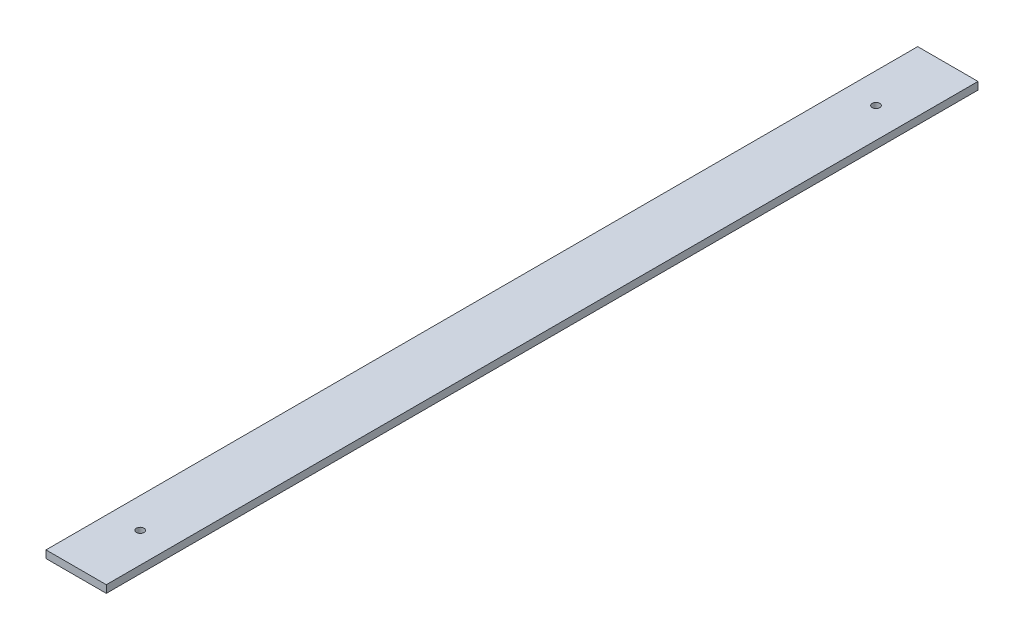
from build123d import *

# Parameters (mm, degrees)
SKETCH4_W             = 200
SKETCH4_H             = 2933.573874127
SKETCH4_R             = 12.5
BOSS_EXTRUDE1_DEPTH   = 25
SKETCH4_H_2           = 2891.000919938
BOSS_EXTRUDE1_2_DEPTH = 25
SKETCH4_H_3           = 2656.8496719
BOSS_EXTRUDE1_3_DEPTH = 25
SKETCH4_H_4           = 2167.26069873
BOSS_EXTRUDE1_4_DEPTH = 25
SKETCH4_H_5           = 1693.636583381
BOSS_EXTRUDE1_5_DEPTH = 25
SKETCH5_W             = 4494.406695046
SKETCH5_H             = 4741.158435166
SKETCH5_W_2           = 1974.013920961
SKETCH5_H_2           = 6468.420616006
CUT_EXTRUDE1_DEPTH    = 10
SKETCH6_W             = 3512.97770999
SKETCH6_H             = 3727.07108035
SKETCH6_W_2           = 1146.73724468
SKETCH6_H_2           = 4594.268007597
CUT_EXTRUDE2_DEPTH    = 26


with BuildPart() as part:
    # Sketch4 → Boss-Extrude1 (new body)
    with BuildSketch(Plane(origin=(0, 0, 0), x_dir=(1, 0, 0), z_dir=(0, 1, 0))):
        with Locations((23132.944645813, -11409.369811035)):
            Rectangle(SKETCH4_W, SKETCH4_H)
        with Locations((23132.944645813, -12678.089615367)):
            Circle(SKETCH4_R, mode=Mode.SUBTRACT)
        with Locations((23132.944645813, -10181.030459334)):
            Circle(SKETCH4_R, mode=Mode.SUBTRACT)
    extrude(amount=BOSS_EXTRUDE1_DEPTH)


with BuildPart() as body_2:
    # Sketch4 → Boss-Extrude1 2 (new body)
    with BuildSketch(Plane(origin=(0, 0, 0), x_dir=(1, 0, 0), z_dir=(0, 1, 0))):
        with Locations((22032.944645813, -11388.083333941)):
            Rectangle(SKETCH4_W, SKETCH4_H_2)
        with Locations((22032.944645813, -12621.228285175)):
            Circle(SKETCH4_R, mode=Mode.SUBTRACT)
        with Locations((22032.944645813, -10181.030459334)):
            Circle(SKETCH4_R, mode=Mode.SUBTRACT)
    extrude(amount=BOSS_EXTRUDE1_2_DEPTH)


with BuildPart() as body_3:
    # Sketch4 → Boss-Extrude1 3 (new body)
    with BuildSketch(Plane(origin=(0, 0, 0), x_dir=(1, 0, 0), z_dir=(0, 1, 0))):
        with Locations((20832.944645813, -11271.007709922)):
            Rectangle(SKETCH4_W, SKETCH4_H_3)
        with Locations((20832.944645813, -12348.754240871)):
            Circle(SKETCH4_R, mode=Mode.SUBTRACT)
        with Locations((20832.944645813, -10181.030459334)):
            Circle(SKETCH4_R, mode=Mode.SUBTRACT)
    extrude(amount=BOSS_EXTRUDE1_3_DEPTH)


with BuildPart() as body_4:
    # Sketch4 → Boss-Extrude1 4 (new body)
    with BuildSketch(Plane(origin=(0, 0, 0), x_dir=(1, 0, 0), z_dir=(0, 1, 0))):
        with Locations((19632.944645813, -11026.213223337)):
            Rectangle(SKETCH4_W, SKETCH4_H_4)
        with Locations((19632.944645813, -11826.915448153)):
            Circle(SKETCH4_R, mode=Mode.SUBTRACT)
        with Locations((19632.944645813, -10181.030459334)):
            Circle(SKETCH4_R, mode=Mode.SUBTRACT)
    extrude(amount=BOSS_EXTRUDE1_4_DEPTH)


with BuildPart() as body_5:
    # Sketch4 → Boss-Extrude1 5 (new body)
    with BuildSketch(Plane(origin=(0, 0, 0), x_dir=(1, 0, 0), z_dir=(0, 1, 0))):
        with Locations((18802.944645813, -10789.401165663)):
            Rectangle(SKETCH4_W, SKETCH4_H_5)
        with Locations((18802.944645813, -11283.669778774)):
            Circle(SKETCH4_R, mode=Mode.SUBTRACT)
        with Locations((18802.944645813, -10181.030459334)):
            Circle(SKETCH4_R, mode=Mode.SUBTRACT)
    extrude(amount=BOSS_EXTRUDE1_5_DEPTH)


with BuildPart() as cut_extrude1_tool:
    # Sketch5 → Cut-Extrude1 (new body)
    with BuildSketch(Plane(origin=(0, 0, 0), x_dir=(1, 0, 0), z_dir=(0, 1, 0))):
        with Locations((19231.869902825, -10968.741703678)):
            Rectangle(SKETCH5_W, SKETCH5_H)
        with Locations((23594.088165664, -11444.620059624)):
            Rectangle(SKETCH5_W_2, SKETCH5_H_2)
    extrude(amount=CUT_EXTRUDE1_DEPTH)


with BuildPart() as part_1:
    add(part.part)

    # Cut-Extrude1: cut by cut_extrude1_tool
    add(cut_extrude1_tool.part, mode=Mode.SUBTRACT)


with BuildPart() as body_3_1:
    add(body_3.part)

    # Cut-Extrude1: cut by cut_extrude1_tool
    add(cut_extrude1_tool.part, mode=Mode.SUBTRACT)


with BuildPart() as body_4_1:
    add(body_4.part)

    # Cut-Extrude1: cut by cut_extrude1_tool
    add(cut_extrude1_tool.part, mode=Mode.SUBTRACT)


with BuildPart() as body_5_1:
    add(body_5.part)

    # Cut-Extrude1: cut by cut_extrude1_tool
    add(cut_extrude1_tool.part, mode=Mode.SUBTRACT)


with BuildPart() as cut_extrude2_tool:
    # Sketch6 → Cut-Extrude2 (new body, through all)
    with BuildSketch(Plane(origin=(0, 0, 0), x_dir=(1, 0, 0), z_dir=(0, 1, 0))):
        with Locations((19642.924182274, -11343.935947445)):
            Rectangle(SKETCH6_W, SKETCH6_H)
        with Locations((23195.80267331, -11003.734808489)):
            Rectangle(SKETCH6_W_2, SKETCH6_H_2)
    extrude(amount=CUT_EXTRUDE2_DEPTH)


with BuildPart() as part_2:
    add(part_1.part)

    # Cut-Extrude2: cut by cut_extrude2_tool
    add(cut_extrude2_tool.part, mode=Mode.SUBTRACT)


with BuildPart() as body_3_2:
    add(body_3_1.part)

    # Cut-Extrude2: cut by cut_extrude2_tool
    add(cut_extrude2_tool.part, mode=Mode.SUBTRACT)


with BuildPart() as body_4_2:
    add(body_4_1.part)

    # Cut-Extrude2: cut by cut_extrude2_tool
    add(cut_extrude2_tool.part, mode=Mode.SUBTRACT)


with BuildPart() as body_5_2:
    add(body_5_1.part)

    # Cut-Extrude2: cut by cut_extrude2_tool
    add(cut_extrude2_tool.part, mode=Mode.SUBTRACT)


solid = body_2.part
